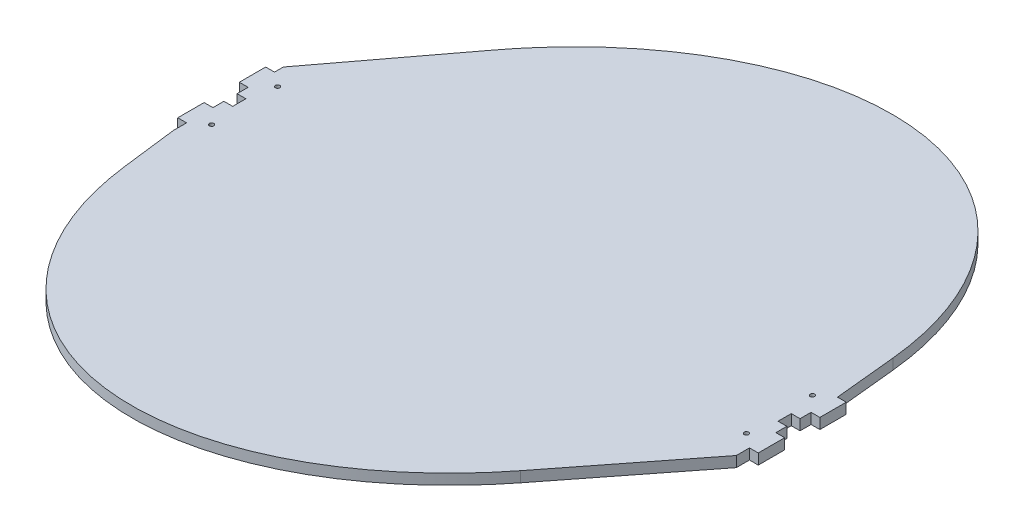
from build123d import *

# Parameters (mm, degrees)
BOSS_EXTRUDE1_DEPTH          = 12
SKETCH2_W                    = 10
SKETCH2_H                    = 15
CUT_EXTRUDE1_DEPTH           = 12
F_5_0_5_DIAMETER_HOLE2_D     = 5
F_5_0_5_DIAMETER_HOLE2_DEPTH = 25
F_5_0_5_DIAMETER_HOLE2_TIP   = 1.502151548


with BuildPart() as part:
    # Sketch1 → Boss-Extrude1 (new body)
    with BuildSketch(Plane(origin=(0, 0, 0), x_dir=(1, 0, 0), z_dir=(0, 1, 0))):
        with BuildLine():
            Line((-320, -65), (-312.170159719, -128.33520269))
            add(Edge.make_bspline(
                [(-312.170159719, -128.33520269), (-232.721291269, -770.993291043), (212.28214963, -202.588475219)],
                knots=[5.492316601, 5.492316601, 5.492316601, 7.67057167, 7.67057167, 7.67057167], degree=2, weights=[1, 0.463258742, 1]))
            Line((212.28214963, -202.588475219), (320, -65))
            Line((320, -65), (320, -50))
            Line((320, -50), (330, -50))
            Line((330, -50), (330, -20))
            Line((330, -20), (320, -20))
            Line((320, -20), (320, 20))
            Line((320, 20), (330, 20))
            Line((330, 20), (330, 50))
            Line((330, 50), (320, 50))
            Line((320, 50), (320, 51))
            Line((320, 51), (313.091302172, 120.09271769))
            add(Edge.make_bspline(
                [(313.091302172, 120.09271769), (244.337364097, 807.689215884), (-217.547896668, 195.738545202)],
                knots=[2.326299806, 2.326299806, 2.326299806, 4.55185667, 4.55185667, 4.55185667], degree=2, weights=[1, 0.442171166, 1]))
            Line((-217.547896668, 195.738545202), (-320, 60))
            Line((-320, 60), (-320, 50))
            Line((-320, 50), (-330, 50))
            Line((-330, 50), (-330, 20))
            Line((-330, 20), (-320, 20))
            Line((-320, 20), (-320, -20))
            Line((-320, -20), (-330, -20))
            Line((-330, -20), (-330, -50))
            Line((-330, -50), (-320, -50))
            Line((-320, -50), (-320, -65))
        make_face()
    extrude(amount=BOSS_EXTRUDE1_DEPTH)

    # Sketch2 → Cut-Extrude1 (cut)
    with BuildSketch(Plane.XZ):
        with Locations((315, 0)):
            Rectangle(SKETCH2_W, SKETCH2_H)
        with Locations((-315, 0)):
            Rectangle(SKETCH2_W, SKETCH2_H)
    extrude(amount=-CUT_EXTRUDE1_DEPTH, mode=Mode.SUBTRACT)

    # Ø5.0 (5) Diameter Hole2
    with Locations(Plane(origin=(0, -12, 0), x_dir=(-1, 0, 0), z_dir=(0, -1, 0))):
        with Locations((304, 37.5), (304, -37.5), (-304, -37.5), (-304, 37.5)):
            Hole(F_5_0_5_DIAMETER_HOLE2_D / 2, depth=F_5_0_5_DIAMETER_HOLE2_DEPTH)
            with Locations((0, 0, -(F_5_0_5_DIAMETER_HOLE2_DEPTH + F_5_0_5_DIAMETER_HOLE2_TIP / 2))):  # 118° drill point
                Cone(0, F_5_0_5_DIAMETER_HOLE2_D / 2, F_5_0_5_DIAMETER_HOLE2_TIP, mode=Mode.SUBTRACT)


solid = part.part
